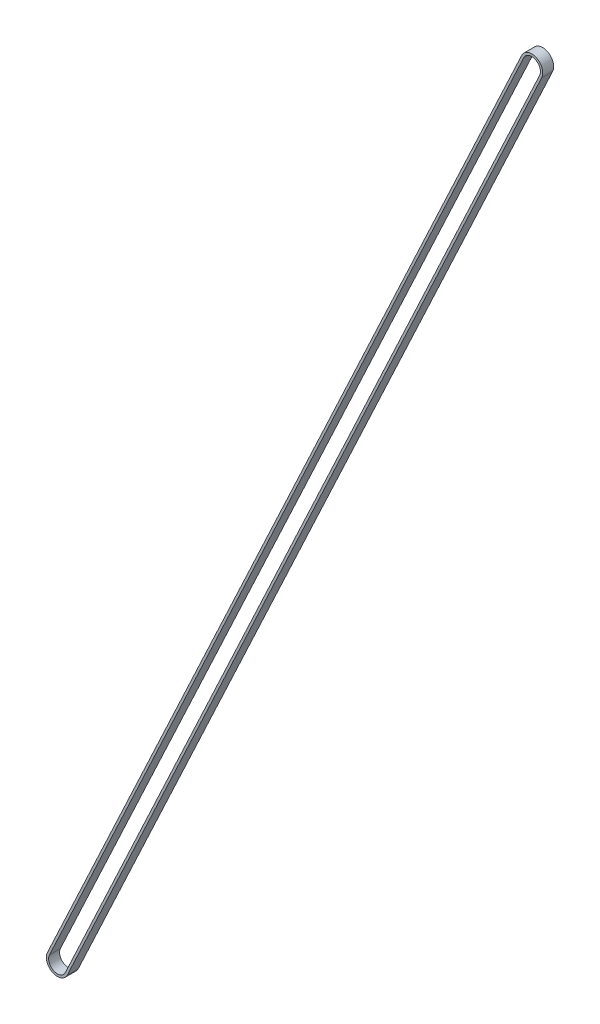
from build123d import *

# Parameters (mm, degrees)
EXTRUDE_THIN1_START = -26.269809
EXTRUDE_THIN1_DEPTH = 19


with BuildPart() as part:
    # Sketch2 → Extrude-Thin1 (new body)
    with BuildSketch(Plane(origin=(-2.158928767, 13.648417367, 0), x_dir=(1, 0, 0), z_dir=(0, 0, 1)).offset(EXTRUDE_THIN1_START)):
        with BuildLine():
            Line((-841.621500671, -1754.223207182), (-17.391917272, 8.133954365))
            ThreePointArc((-17.391917272, 8.133954365), (8.133954365, 17.391917272), (17.391917272, -8.133954365))
            Line((17.391917272, -8.133954365), (-806.837666127, -1770.491115912))
            ThreePointArc((-806.837666127, -1770.491115912), (-832.363537764, -1779.749078819), (-841.621500671, -1754.223207182))
        make_face()
        with BuildLine():
            Line((-837.998184572, -1755.917781008), (-13.768601173, 6.439380539))
            ThreePointArc((-13.768601173, 6.439380539), (6.439380539, 13.768601173), (13.768601173, -6.439380539))
            Line((13.768601173, -6.439380539), (-810.460982226, -1768.796542086))
            ThreePointArc((-810.460982226, -1768.796542086), (-830.668963938, -1776.12576272), (-837.998184572, -1755.917781008))
        make_face(mode=Mode.SUBTRACT)
    extrude(amount=EXTRUDE_THIN1_DEPTH)


solid = part.part
